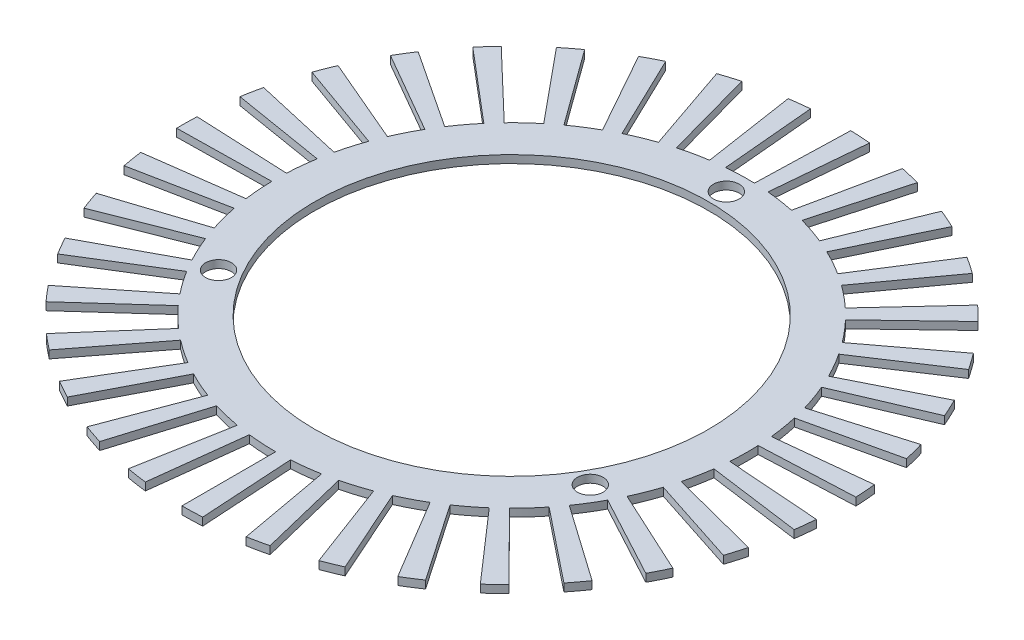
from build123d import *

# Parameters (mm, degrees)
SKETCH1_R           = 30.25
SKETCH1_R_2         = 25.25
EXTRUDE_THIN1_DEPTH = 1
SKETCH2_R           = 1.65
CUT_EXTRUDE3_DEPTH  = 10
BOSS_EXTRUDE1_DEPTH = 1


with BuildPart() as part:
    # Sketch1 → Extrude-Thin1 (new body)
    with BuildSketch(Plane(origin=(0, 0, 0), x_dir=(1, 0, 0), z_dir=(0, 1, 0))):
        Circle(SKETCH1_R)
        Circle(SKETCH1_R_2, mode=Mode.SUBTRACT)
    extrude(amount=-EXTRUDE_THIN1_DEPTH)

    # Sketch2 → Cut-Extrude3 (cut)
    with BuildSketch(Plane(origin=(0, 0, 0), x_dir=(1, 0, 0), z_dir=(0, 1, 0))):
        with Locations((0, 27.5)):
            Circle(SKETCH2_R)
        with Locations((23.815698604, -13.75)):
            Circle(SKETCH2_R)
        with Locations((-23.815698604, -13.75)):
            Circle(SKETCH2_R)
    extrude(amount=-CUT_EXTRUDE3_DEPTH, mode=Mode.SUBTRACT)

    # Sketch5 → Boss-Extrude1 (add)
    with BuildSketch(Plane.XZ.offset(1)):
        with BuildLine():
            Line((0, 42.25), (0, 30.25))
            ThreePointArc((0, 30.25), (0.923790025, 30.235891123), (1.846718321, 30.193577652))
            Line((1.846718321, 30.193577652), (2.579300795, 42.171195233))
            ThreePointArc((2.579300795, 42.171195233), (1.290252183, 42.230294213), (0, 42.25))
        make_face()
        with BuildLine():
            Line((7.544028805, 41.571025118), (5.401346068, 29.763870055))
            ThreePointArc((5.401346068, 29.763870055), (6.307771169, 29.585038835), (7.208312266, 29.378610149))
            Line((7.208312266, 29.378610149), (10.067808041, 41.032934836))
            ThreePointArc((10.067808041, 41.032934836), (8.810027501, 41.321252588), (7.544028805, 41.571025118))
        make_face()
        with BuildLine():
            Line((14.845586317, 39.555923285), (10.629088428, 28.321104837))
            ThreePointArc((10.629088428, 28.321104837), (11.489015358, 27.983299057), (12.338225124, 27.619389942))
            Line((12.338225124, 27.619389942), (17.232727653, 38.575842151))
            ThreePointArc((17.232727653, 38.575842151), (16.046641286, 39.084111906), (14.845586317, 39.555923285))
        make_face()
        with BuildLine():
            Line((21.66999447, 36.26946153), (15.515203142, 25.968076006))
            ThreePointArc((15.515203142, 25.968076006), (16.300993141, 25.482153022), (17.071577275, 24.972459818))
            Line((17.071577275, 24.972459818), (23.843773219, 34.878890159))
            ThreePointArc((23.843773219, 34.878890159), (22.767502816, 35.590775708), (21.66999447, 36.26946153))
        make_face()
        with BuildLine():
            Line((27.797911171, 31.817269439), (19.90264646, 22.780411847))
            ThreePointArc((19.90264646, 22.780411847), (20.589043591, 22.161989622), (21.256234885, 21.522894287))
            Line((21.256234885, 21.522894287), (29.688460294, 30.060901938))
            ThreePointArc((29.688460294, 30.060901938), (28.756598074, 30.953522695), (27.797911171, 31.817269439))
        make_face()
        with BuildLine():
            Line((33.032380134, 26.342444129), (23.650402345, 18.860566506))
            ThreePointArc((23.650402345, 18.860566506), (24.21534524, 18.129521641), (24.757699617, 17.381565225))
            Line((24.757699617, 17.381565225), (34.578935829, 24.276731596))
            ThreePointArc((34.578935829, 24.276731596), (33.821432607, 25.321397994), (33.032380134, 26.342444129))
        make_face()
        with BuildLine():
            Line((37.205161221, 20.020950989), (26.638014839, 14.33452704))
            ThreePointArc((26.638014839, 14.33452704), (27.063345768, 13.514355917), (27.463431512, 12.681578355))
            Line((27.463431512, 12.681578355), (38.358015914, 17.712287124))
            ThreePointArc((38.358015914, 17.712287124), (37.799218469, 18.875422727), (37.205161221, 20.020950989))
        make_face()
        with BuildLine():
            Line((40.182137813, 13.055968012), (28.769459618, 9.34776408))
            ThreePointArc((28.769459618, 9.34776408), (29.041508095, 8.464827674), (29.286466121, 7.573995123))
            Line((29.286466121, 7.573995123), (40.904237806, 10.578555171))
            ThreePointArc((40.904237806, 10.578555171), (40.562106348, 11.822775843), (40.182137813, 13.055968012))
        make_face()
        with BuildLine():
            Line((41.867627435, 5.671355481), (29.976230293, 4.060556291))
            ThreePointArc((29.976230293, 4.060556291), (30.086252457, 3.143232906), (30.168209613, 2.222977455))
            Line((30.168209613, 2.222977455), (42.135763839, 3.104819751))
            ThreePointArc((42.135763839, 3.104819751), (42.021294754, 4.390135215), (41.867627435, 5.671355481))
        make_face()
        with BuildLine():
            Line((42.207457061, -1.895539082), (30.219540263, -1.357161118))
            ThreePointArc((30.219540263, -1.357161118), (30.16399991, -2.279387955), (30.080322025, -3.199488538))
            Line((30.080322025, -3.199488538), (42.013011753, -4.468707131))
            ThreePointArc((42.013011753, -4.468707131), (42.129884171, -3.183607971), (42.207457061, -1.895539082))
        make_face()
        with BuildLine():
            Line((41.19070429, -9.40150946), (29.491569343, -6.731258252))
            ThreePointArc((29.491569343, -6.731258252), (29.272251586, -7.628747412), (29.025628136, -8.519120336))
            Line((29.025628136, -8.519120336), (40.539926901, -11.898606089))
            ThreePointArc((40.539926901, -11.898606089), (40.884384447, -10.655027377), (41.19070429, -9.40150946))
        make_face()
        with BuildLine():
            Line((38.85004839, -16.605307587), (27.81571512, -11.889007208))
            ThreePointArc((27.81571512, -11.889007208), (27.439669012, -12.732912649), (27.038026677, -13.564940597))
            Line((27.038026677, -13.564940597), (37.763855442, -18.946074057))
            ThreePointArc((37.763855442, -18.946074057), (38.324826967, -17.783985436), (38.85004839, -16.605307587))
        make_face()
        with BuildLine():
            Line((35.26071997, -23.275397466), (25.245840925, -16.664633689))
            ThreePointArc((25.245840925, -16.664633689), (24.725152897, -17.427831598), (24.181400794, -18.174772506))
            Line((24.181400794, -18.174772506), (33.774022597, -25.384599615))
            ThreePointArc((33.774022597, -25.384599615), (34.533478014, -24.34135157), (35.26071997, -23.275397466))
        make_face()
        with BuildLine():
            Line((30.538082997, -29.19739692), (21.864544631, -20.904645132))
            ThreePointArc((21.864544631, -20.904645132), (21.215950025, -21.562605699), (20.547564793, -22.200452272))
            Line((20.547564793, -22.200452272), (28.698664876, -31.007243256))
            ThreePointArc((28.698664876, -31.007243256), (29.632194663, -30.116366637), (30.538082997, -29.19739692))
        make_face()
        with BuildLine():
            Line((24.833926909, -34.180968012), (17.780503882, -24.47276408))
            ThreePointArc((17.780503882, -24.47276408), (17.024849063, -25.004339911), (16.253313152, -25.512591236))
            Line((16.253313152, -25.512591236), (22.700908453, -35.633288586))
            ThreePointArc((22.700908453, -35.633288586), (23.778508195, -34.923416901), (24.833926909, -34.180968012))
        make_face()
        with BuildLine():
            Line((18.331587978, -38.065934669), (13.124983108, -27.254308254))
            ThreePointArc((13.124983108, -27.254308254), (12.286555443, -27.642414065), (11.436666654, -28.004734525))
            Line((11.436666654, -28.004734525), (15.973526153, -39.114050701))
            ThreePointArc((15.973526153, -39.114050701), (17.160560908, -38.60799981), (18.331587978, -38.065934669))
        make_face()
        with BuildLine():
            Line((11.240056725, -40.727430864), (8.047614578, -29.159876536))
            ThreePointArc((8.047614578, -29.159876536), (7.153361822, -29.392038287), (6.252436279, -29.596782605))
            Line((6.252436279, -29.596782605), (8.73274158, -41.337655043))
            ThreePointArc((8.73274158, -41.337655043), (9.991059074, -41.051689838), (11.240056725, -40.727430864))
        make_face()
        with BuildLine():
            Line((3.787260801, -42.079913921), (2.711589094, -30.128222393))
            ThreePointArc((2.711589094, -30.128222393), (1.790253267, -30.196978214), (0.867247458, -30.237565739))
            Line((0.867247458, -30.237565739), (1.211279508, -42.23263314))
            ThreePointArc((1.211279508, -42.23263314), (2.500436381, -42.175944778), (3.787260801, -42.079913921))
        make_face()
        with BuildLine():
            Line((-3.787260801, -42.079913921), (-2.711589094, -30.128222393))
            ThreePointArc((-2.711589094, -30.128222393), (-3.630395502, -30.031362415), (-4.54581541, -29.906488631))
            Line((-4.54581541, -29.906488631), (-6.349114085, -41.770219659))
            ThreePointArc((-6.349114085, -41.770219659), (-5.070552395, -41.94463015), (-3.787260801, -42.079913921))
        make_face()
        with BuildLine():
            Line((-11.240056725, -40.727430864), (-8.047614578, -29.159876536))
            ThreePointArc((-8.047614578, -29.159876536), (-8.934360372, -28.900513918), (-9.812772031, -28.614192372))
            Line((-9.812772031, -28.614192372), (-13.705441927, -39.965276949))
            ThreePointArc((-13.705441927, -39.965276949), (-12.478569445, -40.365180597), (-11.240056725, -40.727430864))
        make_face()
        with BuildLine():
            Line((-18.331587978, -38.065934669), (-13.124983108, -27.254308254))
            ThreePointArc((-13.124983108, -27.254308254), (-13.951167549, -26.840779125), (-14.764338084, -26.402212425))
            Line((-14.764338084, -26.402212425), (-20.621265588, -36.875817354))
            ThreePointArc((-20.621265588, -36.875817354), (-19.485515006, -37.488360927), (-18.331587978, -38.065934669))
        make_face()
        with BuildLine():
            Line((-24.833926909, -34.180968012), (-17.780503882, -24.47276408))
            ThreePointArc((-17.780503882, -24.47276408), (-18.519572721, -23.918359606), (-19.241366163, -23.341643647))
            Line((-19.241366163, -23.341643647), (-26.874304807, -32.601138648))
            ThreePointArc((-26.874304807, -32.601138648), (-25.866180081, -33.406634491), (-24.833926909, -34.180968012))
        make_face()
        with BuildLine():
            Line((-30.538082997, -29.19739692), (-21.864544631, -20.904645132))
            ThreePointArc((-21.864544631, -20.904645132), (-22.492743588, -20.227184329), (-23.099960902, -19.530855237))
            Line((-23.099960902, -19.530855237), (-32.263581756, -27.278632522))
            ThreePointArc((-32.263581756, -27.278632522), (-31.415484846, -28.251191335), (-30.538082997, -29.19739692))
        make_face()
        with BuildLine():
            Line((-35.26071997, -23.275397466), (-25.245840925, -16.664633689))
            ThreePointArc((-25.245840925, -16.664633689), (-25.74297917, -15.885890704), (-26.216103891, -15.09232907))
            Line((-26.216103891, -15.09232907), (-36.615880642, -21.079368701))
            ThreePointArc((-36.615880642, -21.079368701), (-35.95507008, -22.187731645), (-35.26071997, -23.275397466))
        make_face()
        with BuildLine():
            Line((-38.85004839, -16.605307587), (-27.81571512, -11.889007208))
            ThreePointArc((-27.81571512, -11.889007208), (-28.165814219, -11.034011482), (-28.48963973, -10.168723028))
            Line((-28.48963973, -10.168723028), (-39.791314995, -14.202596626))
            ThreePointArc((-39.791314995, -14.202596626), (-39.339029777, -15.411140004), (-38.85004839, -16.605307587))
        make_face()
        with BuildLine():
            Line((-41.19070429, -9.40150946), (-29.491569344, -6.731258252))
            ThreePointArc((-29.491569344, -6.731258252), (-29.683376824, -5.827490052), (-29.847495107, -4.918285862))
            Line((-29.847495107, -4.918285862), (-41.687823745, -6.86934141))
            ThreePointArc((-41.687823745, -6.86934141), (-41.458600689, -8.139221642), (-41.19070429, -9.40150946))
        make_face()
        with BuildLine():
            Line((-42.207457061, -1.895539082), (-30.219540263, -1.357161118))
            ThreePointArc((-30.219540263, -1.357161118), (-30.246891275, -0.433668296), (-30.246027433, 0.490229059))
            Line((-30.246027433, 0.490229059), (-42.244451538, 0.684700091))
            ThreePointArc((-42.244451538, 0.684700091), (-42.245658062, -0.605702), (-42.207457061, -1.895539082))
        make_face()
        with BuildLine():
            Line((-41.867627435, 5.671355481), (-29.976230293, 4.060556291))
            ThreePointArc((-29.976230293, 4.060556291), (-29.838245753, 4.974091915), (-29.67242755, 5.882987615))
            Line((-29.67242755, 5.882987615), (-41.443307901, 8.216734768))
            ThreePointArc((-41.443307901, 8.216734768), (-41.674905225, 6.947285402), (-41.867627435, 5.671355481))
        make_face()
        with BuildLine():
            Line((-40.182137813, 13.055968012), (-28.769459618, 9.34776408))
            ThreePointArc((-28.769459618, 9.34776408), (-28.470574462, 10.22198072), (-28.145131431, 11.086662108))
            Line((-28.145131431, 11.086662108), (-39.310142247, 15.484676829))
            ThreePointArc((-39.310142247, 15.484676829), (-39.764686645, 14.276981336), (-40.182137813, 13.055968012))
        make_face()
        with BuildLine():
            Line((-37.205161221, 20.020950989), (-26.638014839, 14.33452704))
            ThreePointArc((-26.638014839, 14.33452704), (-26.187835481, 15.141326653), (-25.713227631, 15.934002159))
            Line((-25.713227631, 15.934002159), (-35.913516278, 22.254928636))
            ThreePointArc((-35.913516278, 22.254928636), (-36.576398317, 21.147803342), (-37.205161221, 20.020950989))
        make_face()
        with BuildLine():
            Line((-33.032380134, 26.342444129), (-23.650402345, 18.860566506))
            ThreePointArc((-23.650402345, 18.860566506), (-23.063397921, 19.57401789), (-22.454879537, 20.26921027))
            Line((-22.454879537, 20.26921027), (-31.362600345, 28.309888725))
            ThreePointArc((-31.362600345, 28.309888725), (-32.212514451, 27.338917548), (-33.032380134, 26.342444129))
        make_face()
        with BuildLine():
            Line((-27.797911171, 31.817269439), (-19.90264646, 22.780411847))
            ThreePointArc((-19.90264646, 22.780411847), (-19.197683775, 23.377584086), (-18.474813139, 23.952949286))
            Line((-18.474813139, 23.952949286), (-25.803664632, 33.454945697))
            ThreePointArc((-25.803664632, 33.454945697), (-26.813293867, 32.65133645), (-27.797911171, 31.817269439))
        make_face()
        with BuildLine():
            Line((-21.66999447, 36.26946153), (-15.515203142, 25.968076006))
            ThreePointArc((-15.515203142, 25.968076006), (-14.714940276, 26.429775494), (-13.900951045, 26.866820802))
            Line((-13.900951045, 26.866820802), (-19.415377906, 37.524733187))
            ThreePointArc((-19.415377906, 37.524733187), (-20.552271956, 36.914314533), (-21.66999447, 36.26946153))
        make_face()
        with BuildLine():
            Line((-14.845586317, 39.555923285), (-10.629088428, 28.321104837))
            ThreePointArc((-10.629088428, 28.321104837), (-9.75924649, 28.632492171), (-8.880300948, 28.917170593))
            Line((-8.880300948, 28.917170593), (-12.40306496, 40.388444877))
            ThreePointArc((-12.40306496, 40.388444877), (-13.630683114, 39.990836173), (-14.845586317, 39.555923285))
        make_face()
        with BuildLine():
            Line((-7.544028805, 41.571025118), (-5.401346068, 29.763870055))
            ThreePointArc((-5.401346068, 29.763870055), (-4.489882492, 29.914936992), (-3.574230671, 30.038098727))
            Line((-3.574230671, 30.038098727), (-4.9921073, 41.954038717))
            ThreePointArc((-4.9921073, 41.954038717), (-6.270992901, 41.782019435), (-7.544028805, 41.571025118))
        make_face()
    extrude(amount=-BOSS_EXTRUDE1_DEPTH)


solid = part.part
